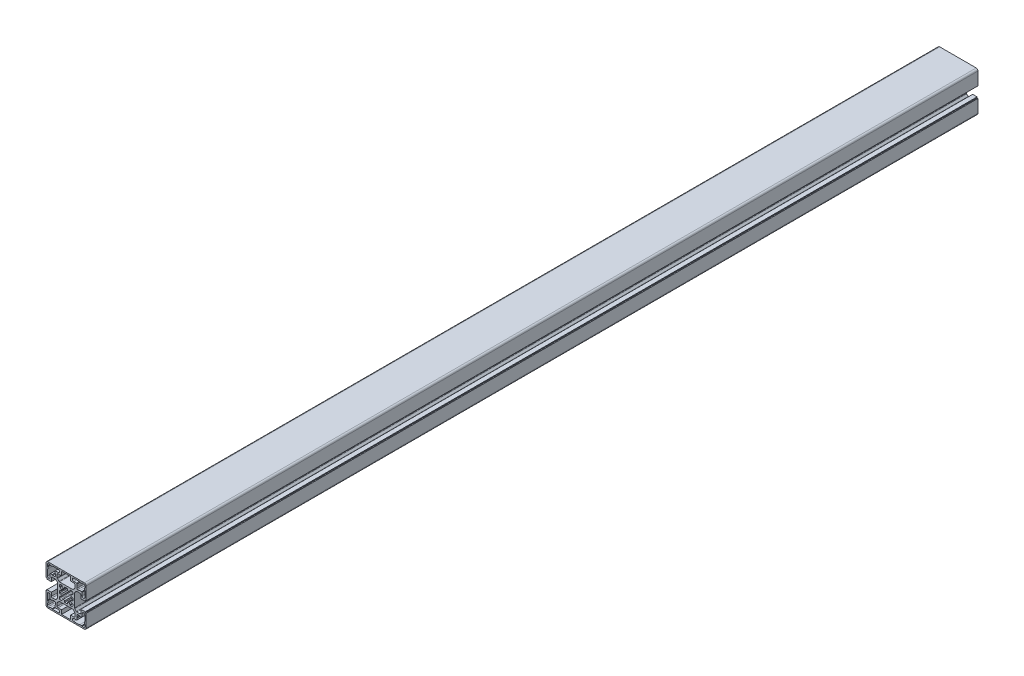
from build123d import *

# Parameters (mm, degrees)
EXTRUDE_1_DEPTH = 1000


with BuildPart() as part:
    # 草图1 → 拉伸1 (new body)
    with BuildSketch(Plane.XY):
        with BuildLine():
            Line((46.413692815, 42.427108363), (46.413692815, 28.027108363))
            ThreePointArc((46.413692815, 28.027108363), (45.827906377, 26.612894801), (44.413692815, 26.027108363))
            Line((44.413692815, 26.027108363), (3.413692814, 26.027108363))
            ThreePointArc((3.413692814, 26.027108363), (1.999479252, 26.612894801), (1.413692814, 28.027108363))
            Line((1.413692814, 28.027108363), (1.413692814, 42.427108363))
            Line((1.413692814, 42.427108363), (2.413692814, 42.427108363))
            Line((2.413692814, 42.427108363), (2.413692814, 43.427108363))
            Line((2.413692814, 43.427108363), (7.413692814, 43.427108363))
            Line((7.413692814, 43.427108363), (7.413692814, 39.527108363))
            ThreePointArc((7.413692814, 39.527108363), (7.706586033, 38.820001582), (8.413692814, 38.527108363))
            Line((8.413692814, 38.527108363), (11.731712299, 38.527108363))
            ThreePointArc((11.731712299, 38.527108363), (12.114395732, 38.603228831), (12.43881908, 38.820001582))
            Line((12.43881908, 38.820001582), (14.120799595, 40.501982097))
            ThreePointArc((14.120799595, 40.501982097), (14.337572347, 40.826405446), (14.413692814, 41.209088878))
            Line((14.413692814, 41.209088878), (14.413692814, 55.845127848))
            ThreePointArc((14.413692814, 55.845127848), (14.337572347, 56.22781128), (14.120799595, 56.552234629))
            Line((14.120799595, 56.552234629), (12.43881908, 58.234215144))
            ThreePointArc((12.43881908, 58.234215144), (12.114395732, 58.450987896), (11.731712299, 58.527108363))
            Line((11.731712299, 58.527108363), (8.413692814, 58.527108363))
            ThreePointArc((8.413692814, 58.527108363), (7.706586033, 58.234215144), (7.413692814, 57.527108363))
            Line((7.413692814, 57.527108363), (7.413692814, 53.627108363))
            Line((7.413692814, 53.627108363), (2.413692814, 53.627108363))
            Line((2.413692814, 53.627108363), (2.413692814, 54.627108363))
            Line((2.413692814, 54.627108363), (1.413692814, 54.627108363))
            Line((1.413692814, 54.627108363), (1.413692814, 69.027108363))
            ThreePointArc((1.413692814, 69.027108363), (1.999479252, 70.441321926), (3.413692814, 71.027108363))
            Line((3.413692814, 71.027108363), (44.413692815, 71.027108363))
            ThreePointArc((44.413692815, 71.027108363), (45.827906377, 70.441321926), (46.413692815, 69.027108363))
            Line((46.413692815, 69.027108363), (46.413692815, 54.627108363))
            Line((46.413692815, 54.627108363), (45.413692815, 54.627108363))
            Line((45.413692815, 54.627108363), (45.413692815, 53.627108363))
            Line((45.413692815, 53.627108363), (40.413692815, 53.627108363))
            Line((40.413692815, 53.627108363), (40.413692815, 57.527108363))
            ThreePointArc((40.413692815, 57.527108363), (40.120799596, 58.234215144), (39.413692815, 58.527108363))
            Line((39.413692815, 58.527108363), (36.09567333, 58.527108363))
            ThreePointArc((36.09567333, 58.527108363), (35.712989897, 58.450987896), (35.388566549, 58.234215144))
            Line((35.388566549, 58.234215144), (33.706586033, 56.552234629))
            ThreePointArc((33.706586033, 56.552234629), (33.489813282, 56.22781128), (33.413692815, 55.845127848))
            Line((33.413692815, 55.845127848), (33.413692815, 41.209088878))
            ThreePointArc((33.413692815, 41.209088878), (33.489813282, 40.826405446), (33.706586033, 40.501982097))
            Line((33.706586033, 40.501982097), (35.388566549, 38.820001582))
            ThreePointArc((35.388566549, 38.820001582), (35.712989897, 38.603228831), (36.09567333, 38.527108363))
            Line((36.09567333, 38.527108363), (39.413692815, 38.527108363))
            ThreePointArc((39.413692815, 38.527108363), (40.120799596, 38.820001582), (40.413692815, 39.527108363))
            Line((40.413692815, 39.527108363), (40.413692815, 43.427108363))
            Line((40.413692815, 43.427108363), (45.413692815, 43.427108363))
            Line((45.413692815, 43.427108363), (45.413692815, 42.427108363))
            Line((45.413692815, 42.427108363), (46.413692815, 42.427108363))
        make_face()
        with BuildLine():
            Line((30.535013158, 44.027108363), (29.082272168, 45.479849354))
            ThreePointArc((29.082272168, 45.479849354), (29.45697001, 46.231007769), (29.723167834, 47.027108363))
            Line((29.723167834, 47.027108363), (31.413692814, 47.027108363))
            Line((31.413692814, 47.027108363), (31.413692814, 50.027108363))
            Line((31.413692814, 50.027108363), (29.723167834, 50.027108363))
            ThreePointArc((29.723167834, 50.027108363), (29.45697001, 50.823208957), (29.082272168, 51.574367373))
            Line((29.082272168, 51.574367373), (30.535013158, 53.027108363))
            Line((30.535013158, 53.027108363), (31.413692814, 53.027108363))
            Line((31.413692814, 53.027108363), (31.413692814, 55.027108363))
            ThreePointArc((31.413692814, 55.027108363), (31.120799596, 55.734215144), (30.413692814, 56.027108363))
            Line((30.413692814, 56.027108363), (28.413692814, 56.027108363))
            Line((28.413692814, 56.027108363), (28.413692814, 55.148428707))
            Line((28.413692814, 55.148428707), (26.960951824, 53.695687716))
            ThreePointArc((26.960951824, 53.695687716), (26.209793409, 54.070385558), (25.413692814, 54.336583382))
            Line((25.413692814, 54.336583382), (25.413692814, 56.027108363))
            Line((25.413692814, 56.027108363), (22.413692814, 56.027108363))
            Line((22.413692814, 56.027108363), (22.413692814, 54.336583382))
            ThreePointArc((22.413692814, 54.336583382), (21.61759222, 54.070385558), (20.866433805, 53.695687716))
            Line((20.866433805, 53.695687716), (19.413692814, 55.148428707))
            Line((19.413692814, 55.148428707), (19.413692814, 56.027108363))
            Line((19.413692814, 56.027108363), (17.413692814, 56.027108363))
            ThreePointArc((17.413692814, 56.027108363), (16.706586033, 55.734215144), (16.413692814, 55.027108363))
            Line((16.413692814, 55.027108363), (16.413692814, 53.027108363))
            Line((16.413692814, 53.027108363), (17.292372471, 53.027108363))
            Line((17.292372471, 53.027108363), (18.745113461, 51.574367373))
            ThreePointArc((18.745113461, 51.574367373), (18.370415619, 50.823208957), (18.104217795, 50.027108363))
            Line((18.104217795, 50.027108363), (16.413692814, 50.027108363))
            Line((16.413692814, 50.027108363), (16.413692814, 47.027108363))
            Line((16.413692814, 47.027108363), (18.104217795, 47.027108363))
            ThreePointArc((18.104217795, 47.027108363), (18.370415619, 46.231007769), (18.745113461, 45.479849354))
            Line((18.745113461, 45.479849354), (17.292372471, 44.027108363))
            Line((17.292372471, 44.027108363), (16.413692814, 44.027108363))
            Line((16.413692814, 44.027108363), (16.413692814, 42.027108363))
            ThreePointArc((16.413692814, 42.027108363), (16.706586033, 41.320001582), (17.413692814, 41.027108363))
            Line((17.413692814, 41.027108363), (19.413692814, 41.027108363))
            Line((19.413692814, 41.027108363), (19.413692814, 41.905788019))
            Line((19.413692814, 41.905788019), (20.866433805, 43.35852901))
            ThreePointArc((20.866433805, 43.35852901), (21.61759222, 42.983831168), (22.413692814, 42.717633344))
            Line((22.413692814, 42.717633344), (22.413692814, 41.027108363))
            Line((22.413692814, 41.027108363), (25.413692814, 41.027108363))
            Line((25.413692814, 41.027108363), (25.413692814, 42.717633344))
            ThreePointArc((25.413692814, 42.717633344), (26.209793409, 42.983831168), (26.960951824, 43.35852901))
            Line((26.960951824, 43.35852901), (28.413692814, 41.905788019))
            Line((28.413692814, 41.905788019), (28.413692814, 41.027108363))
            Line((28.413692814, 41.027108363), (30.413692814, 41.027108363))
            ThreePointArc((30.413692814, 41.027108363), (31.120799596, 41.320001582), (31.413692814, 42.027108363))
            Line((31.413692814, 42.027108363), (31.413692814, 44.027108363))
            Line((31.413692814, 44.027108363), (30.535013158, 44.027108363))
        make_face(mode=Mode.SUBTRACT)
        with BuildLine():
            Line((11.413692814, 66.027108363), (11.913692814, 66.527108364))
            Line((11.913692814, 66.527108364), (15.313692814, 66.527108364))
            ThreePointArc((15.313692814, 66.527108364), (16.813692814, 68.027108363), (15.313692814, 69.527108363))
            Line((15.313692814, 69.527108363), (8.913692815, 69.527108363))
            Line((8.913692815, 69.527108363), (8.413692814, 69.027108363))
            Line((8.413692814, 69.027108363), (6.413692814, 69.027108363))
            Line((6.413692814, 69.027108363), (5.913692814, 69.527108363))
            Line((5.913692814, 69.527108363), (3.913692814, 69.527108363))
            ThreePointArc((3.913692814, 69.527108363), (3.206586033, 69.234215144), (2.913692814, 68.527108363))
            Line((2.913692814, 68.527108363), (2.913692814, 66.527108363))
            Line((2.913692814, 66.527108363), (3.413692814, 66.027108363))
            Line((3.413692814, 66.027108363), (3.413692814, 64.027108363))
            Line((3.413692814, 64.027108363), (2.913692814, 63.527108363))
            Line((2.913692814, 63.527108363), (2.913692814, 57.127108364))
            ThreePointArc((2.913692814, 57.127108364), (4.413692814, 55.627108364), (5.913692814, 57.127108364))
            Line((5.913692814, 57.127108364), (5.913692814, 60.527108363))
            Line((5.913692814, 60.527108363), (6.413692814, 61.027108363))
            Line((6.413692814, 61.027108363), (8.413692814, 61.027108363))
            Line((8.413692814, 61.027108363), (8.913692814, 60.527108363))
            Line((8.913692814, 60.527108363), (10.913692814, 60.527108363))
            ThreePointArc((10.913692814, 60.527108363), (11.620799595, 60.820001582), (11.913692814, 61.527108363))
            Line((11.913692814, 61.527108363), (11.913692814, 63.527108363))
            Line((11.913692814, 63.527108363), (11.413692814, 64.027108363))
            Line((11.413692814, 64.027108363), (11.413692814, 66.027108363))
        make_face(mode=Mode.SUBTRACT)
        with BuildLine():
            Line((15.313692814, 30.527108363), (11.913692815, 30.527108363))
            Line((11.913692815, 30.527108363), (11.413692814, 31.027108363))
            Line((11.413692814, 31.027108363), (11.413692814, 33.027108363))
            Line((11.413692814, 33.027108363), (11.913692815, 33.527108363))
            Line((11.913692815, 33.527108363), (11.913692815, 35.527108363))
            ThreePointArc((11.913692815, 35.527108363), (11.620799596, 36.234215144), (10.913692815, 36.527108363))
            Line((10.913692815, 36.527108363), (8.913692815, 36.527108363))
            Line((8.913692815, 36.527108363), (8.413692815, 36.027108363))
            Line((8.413692815, 36.027108363), (6.413692814, 36.027108363))
            Line((6.413692814, 36.027108363), (5.913692814, 36.527108363))
            Line((5.913692814, 36.527108363), (5.913692814, 39.927108363))
            ThreePointArc((5.913692814, 39.927108363), (4.413692814, 41.427108363), (2.913692814, 39.927108363))
            Line((2.913692814, 39.927108363), (2.913692814, 33.527108363))
            Line((2.913692814, 33.527108363), (3.413692814, 33.027108363))
            Line((3.413692814, 33.027108363), (3.413692814, 31.027108363))
            Line((3.413692814, 31.027108363), (2.913692814, 30.527108363))
            Line((2.913692814, 30.527108363), (2.913692814, 28.527108363))
            ThreePointArc((2.913692814, 28.527108363), (3.206586033, 27.820001582), (3.913692814, 27.527108363))
            Line((3.913692814, 27.527108363), (5.913692814, 27.527108363))
            Line((5.913692814, 27.527108363), (6.413692814, 28.027108363))
            Line((6.413692814, 28.027108363), (8.413692814, 28.027108363))
            Line((8.413692814, 28.027108363), (8.913692815, 27.527108363))
            Line((8.913692815, 27.527108363), (15.313692814, 27.527108363))
            ThreePointArc((15.313692814, 27.527108363), (16.813692814, 29.027108363), (15.313692814, 30.527108363))
        make_face(mode=Mode.SUBTRACT)
        with BuildLine():
            Line((41.913692815, 39.927108363), (41.913692815, 36.527108363))
            Line((41.913692815, 36.527108363), (41.413692815, 36.027108363))
            Line((41.413692815, 36.027108363), (39.413692815, 36.027108363))
            Line((39.413692815, 36.027108363), (38.913692814, 36.527108363))
            Line((38.913692814, 36.527108363), (36.913692815, 36.527108363))
            ThreePointArc((36.913692815, 36.527108363), (36.206586033, 36.234215144), (35.913692815, 35.527108363))
            Line((35.913692815, 35.527108363), (35.913692815, 33.527108364))
            Line((35.913692815, 33.527108364), (36.413692815, 33.027108363))
            Line((36.413692815, 33.027108363), (36.413692815, 31.027108363))
            Line((36.413692815, 31.027108363), (35.913692815, 30.527108363))
            Line((35.913692815, 30.527108363), (32.513692815, 30.527108363))
            ThreePointArc((32.513692815, 30.527108363), (31.013692815, 29.027108363), (32.513692815, 27.527108363))
            Line((32.513692815, 27.527108363), (38.913692814, 27.527108363))
            Line((38.913692814, 27.527108363), (39.413692814, 28.027108363))
            Line((39.413692814, 28.027108363), (41.413692814, 28.027108363))
            Line((41.413692814, 28.027108363), (41.913692815, 27.527108363))
            Line((41.913692815, 27.527108363), (43.913692815, 27.527108363))
            ThreePointArc((43.913692815, 27.527108363), (44.620799596, 27.820001582), (44.913692815, 28.527108363))
            Line((44.913692815, 28.527108363), (44.913692815, 30.527108363))
            Line((44.913692815, 30.527108363), (44.413692814, 31.027108363))
            Line((44.413692814, 31.027108363), (44.413692814, 33.027108363))
            Line((44.413692814, 33.027108363), (44.913692815, 33.527108364))
            Line((44.913692815, 33.527108364), (44.913692815, 39.927108363))
            ThreePointArc((44.913692815, 39.927108363), (43.413692815, 41.427108363), (41.913692815, 39.927108363))
        make_face(mode=Mode.SUBTRACT)
        with BuildLine():
            Line((32.513692815, 66.527108363), (35.913692815, 66.527108363))
            Line((35.913692815, 66.527108363), (36.413692815, 66.027108363))
            Line((36.413692815, 66.027108363), (36.413692815, 64.027108363))
            Line((36.413692815, 64.027108363), (35.913692815, 63.527108363))
            Line((35.913692815, 63.527108363), (35.913692815, 61.527108363))
            ThreePointArc((35.913692815, 61.527108363), (36.206586033, 60.820001582), (36.913692815, 60.527108363))
            Line((36.913692815, 60.527108363), (38.913692814, 60.527108363))
            Line((38.913692814, 60.527108363), (39.413692815, 61.027108364))
            Line((39.413692815, 61.027108364), (41.413692815, 61.027108364))
            Line((41.413692815, 61.027108364), (41.913692815, 60.527108363))
            Line((41.913692815, 60.527108363), (41.913692815, 57.127108364))
            ThreePointArc((41.913692815, 57.127108364), (43.413692815, 55.627108364), (44.913692815, 57.127108364))
            Line((44.913692815, 57.127108364), (44.913692815, 63.527108363))
            Line((44.913692815, 63.527108363), (44.413692815, 64.027108363))
            Line((44.413692815, 64.027108363), (44.413692815, 66.027108363))
            Line((44.413692815, 66.027108363), (44.913692815, 66.527108363))
            Line((44.913692815, 66.527108363), (44.913692815, 68.527108363))
            ThreePointArc((44.913692815, 68.527108363), (44.620799596, 69.234215145), (43.913692815, 69.527108363))
            Line((43.913692815, 69.527108363), (41.913692815, 69.527108363))
            Line((41.913692815, 69.527108363), (41.413692814, 69.027108363))
            Line((41.413692814, 69.027108363), (39.413692814, 69.027108363))
            Line((39.413692814, 69.027108363), (38.913692814, 69.527108363))
            Line((38.913692814, 69.527108363), (32.513692815, 69.527108363))
            ThreePointArc((32.513692815, 69.527108363), (31.013692815, 68.027108363), (32.513692815, 66.527108363))
        make_face(mode=Mode.SUBTRACT)
        with BuildLine():
            Line((29.013692814, 69.527108363), (18.813692815, 69.527108363))
            Line((18.813692815, 69.527108363), (18.813692815, 65.027108363))
            Line((18.813692815, 65.027108363), (14.913692814, 65.027108363))
            ThreePointArc((14.913692814, 65.027108363), (14.206586033, 64.734215145), (13.913692814, 64.027108363))
            Line((13.913692814, 64.027108363), (13.913692814, 60.709088878))
            ThreePointArc((13.913692814, 60.709088878), (13.989813282, 60.326405446), (14.206586033, 60.001982097))
            Line((14.206586033, 60.001982097), (15.888566548, 58.320001582))
            ThreePointArc((15.888566548, 58.320001582), (16.212989897, 58.103228831), (16.59567333, 58.027108363))
            Line((16.59567333, 58.027108363), (31.231712299, 58.027108363))
            ThreePointArc((31.231712299, 58.027108363), (31.614395732, 58.103228831), (31.938819081, 58.320001582))
            Line((31.938819081, 58.320001582), (33.620799596, 60.001982097))
            ThreePointArc((33.620799596, 60.001982097), (33.837572347, 60.326405446), (33.913692814, 60.709088878))
            Line((33.913692814, 60.709088878), (33.913692814, 64.027108363))
            ThreePointArc((33.913692814, 64.027108363), (33.620799596, 64.734215145), (32.913692814, 65.027108363))
            Line((32.913692814, 65.027108363), (29.013692814, 65.027108363))
            Line((29.013692814, 65.027108363), (29.013692814, 69.527108363))
        make_face(mode=Mode.SUBTRACT)
        with BuildLine():
            Line((29.013692814, 32.027108363), (32.913692815, 32.027108363))
            ThreePointArc((32.913692815, 32.027108363), (33.620799596, 32.320001582), (33.913692815, 33.027108363))
            Line((33.913692815, 33.027108363), (33.913692815, 36.345127848))
            ThreePointArc((33.913692815, 36.345127848), (33.837572347, 36.72781128), (33.620799596, 37.052234629))
            Line((33.620799596, 37.052234629), (31.938819081, 38.734215144))
            ThreePointArc((31.938819081, 38.734215144), (31.614395732, 38.950987895), (31.231712299, 39.027108363))
            Line((31.231712299, 39.027108363), (16.59567333, 39.027108363))
            ThreePointArc((16.59567333, 39.027108363), (16.212989897, 38.950987895), (15.888566548, 38.734215144))
            Line((15.888566548, 38.734215144), (14.206586033, 37.052234629))
            ThreePointArc((14.206586033, 37.052234629), (13.989813282, 36.72781128), (13.913692814, 36.345127848))
            Line((13.913692814, 36.345127848), (13.913692814, 33.027108363))
            ThreePointArc((13.913692814, 33.027108363), (14.206586033, 32.320001582), (14.913692814, 32.027108363))
            Line((14.913692814, 32.027108363), (18.813692815, 32.027108363))
            Line((18.813692815, 32.027108363), (18.813692815, 27.527108363))
            Line((18.813692815, 27.527108363), (29.013692814, 27.527108363))
            Line((29.013692814, 27.527108363), (29.013692814, 32.027108363))
        make_face(mode=Mode.SUBTRACT)
    extrude(amount=EXTRUDE_1_DEPTH)


solid = part.part
